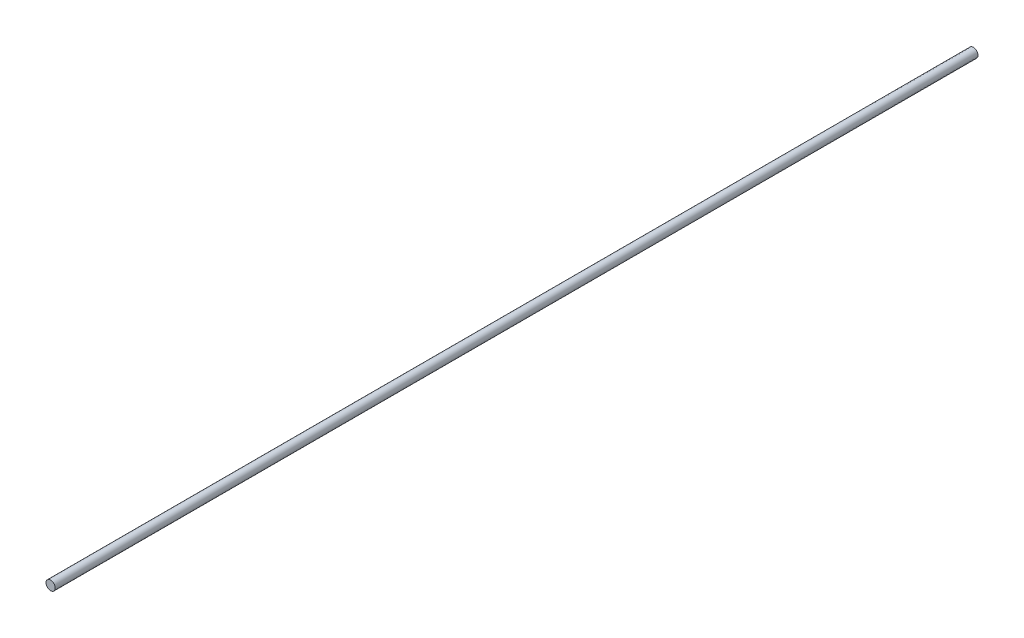
from build123d import *

# Parameters (mm, degrees)
SKETCH3_R                = 1.905
BOSS_EXTRUDE1_DEPTH      = 190.5
BOSS_EXTRUDE1_DEPTH_BACK = 190.5


with BuildPart() as part:
    # Sketch3 → Boss-Extrude1 (new body, two sides)
    with BuildSketch(Plane.XY) as boss_extrude1_sk:
        Circle(SKETCH3_R)
    extrude(amount=BOSS_EXTRUDE1_DEPTH)
    extrude(boss_extrude1_sk.sketch, amount=-BOSS_EXTRUDE1_DEPTH_BACK)


solid = part.part
